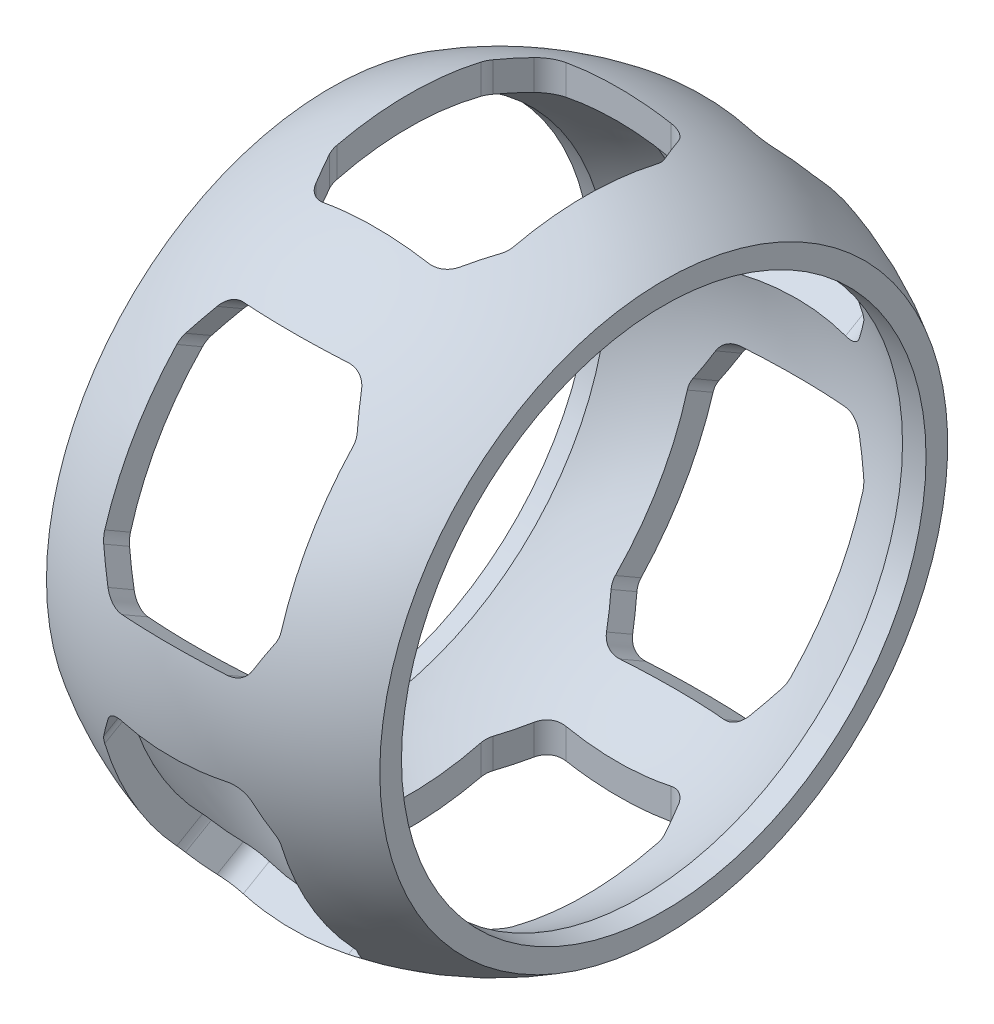
from build123d import *

# Parameters (mm, degrees)
CUT_EXTRUDE1_DEPTH = 53.037762686
CIRPATTERN1_COUNT  = 3


with BuildPart() as part:
    # Sketch2 → Revolve1 (revolve)
    with BuildSketch(Plane(origin=(0, 0, 0), x_dir=(1, 0, 0), z_dir=(0, 1, 0))):
        with BuildLine():
            Line((0, 25.759694725), (0, 23.614499433))
            Line((0, 23.614499433), (1.561649314, 23.614499433))
            ThreePointArc((1.561649314, 23.614499433), (14.808149369, 27.473813657), (28.105558645, 23.793735324))
            Line((28.105558645, 23.793735324), (30.238726182, 23.793735324))
            Line((30.238726182, 23.793735324), (30.238726182, 25.759694725))
            ThreePointArc((30.238726182, 25.759694725), (15.119363091, 29.946186453), (0, 25.759694725))
        make_face()
    revolve(axis=Axis((0, 0, 0), (1, 0, 0)))

    # Sketch3 → Cut-Extrude1 (cut, symmetric)
    with BuildSketch(Plane(origin=(0, 0, 0), x_dir=(1, 0, 0), z_dir=(0, 1, 0))):
        with BuildLine():
            Line((7.330508709, 7.422291236), (8.566576686, 9.894427191))
            ThreePointArc((8.566576686, 9.894427191), (9.303968844, 10.701301617), (10.355431068, 11))
            Line((10.355431068, 11), (19.883295113, 11))
            ThreePointArc((19.883295113, 11), (20.934757338, 10.701301617), (21.672149495, 9.894427191))
            Line((21.672149495, 9.894427191), (22.908217473, 7.422291236))
            ThreePointArc((22.908217473, 7.422291236), (23.06586107, 6.987369886), (23.119363091, 6.527864045))
            Line((23.119363091, 6.527864045), (23.119363091, -6.527864045))
            ThreePointArc((23.119363091, -6.527864045), (23.06586107, -6.987369886), (22.908217473, -7.422291236))
            Line((22.908217473, -7.422291236), (21.672149495, -9.894427191))
            ThreePointArc((21.672149495, -9.894427191), (20.934757338, -10.701301617), (19.883295113, -11))
            Line((19.883295113, -11), (10.355431068, -11))
            ThreePointArc((10.355431068, -11), (9.303968844, -10.701301617), (8.566576686, -9.894427191))
            Line((8.566576686, -9.894427191), (7.330508709, -7.422291236))
            ThreePointArc((7.330508709, -7.422291236), (7.172865112, -6.987369886), (7.119363091, -6.527864045))
            Line((7.119363091, -6.527864045), (7.119363091, 6.527864045))
            ThreePointArc((7.119363091, 6.527864045), (7.172865112, 6.987369886), (7.330508709, 7.422291236))
        make_face()
    cut_extrude1 = extrude(amount=CUT_EXTRUDE1_DEPTH, both=True, mode=Mode.SUBTRACT)

    # CirPattern1: Cut-Extrude1 ×3 about axis
    cirpattern1_axis = Axis((30.238726182, 0, 0), (-1, 0, 0))
    for i in range(1, CIRPATTERN1_COUNT):
        add(cut_extrude1.rotate(cirpattern1_axis, i * 360 / CIRPATTERN1_COUNT), mode=Mode.SUBTRACT)


solid = part.part
